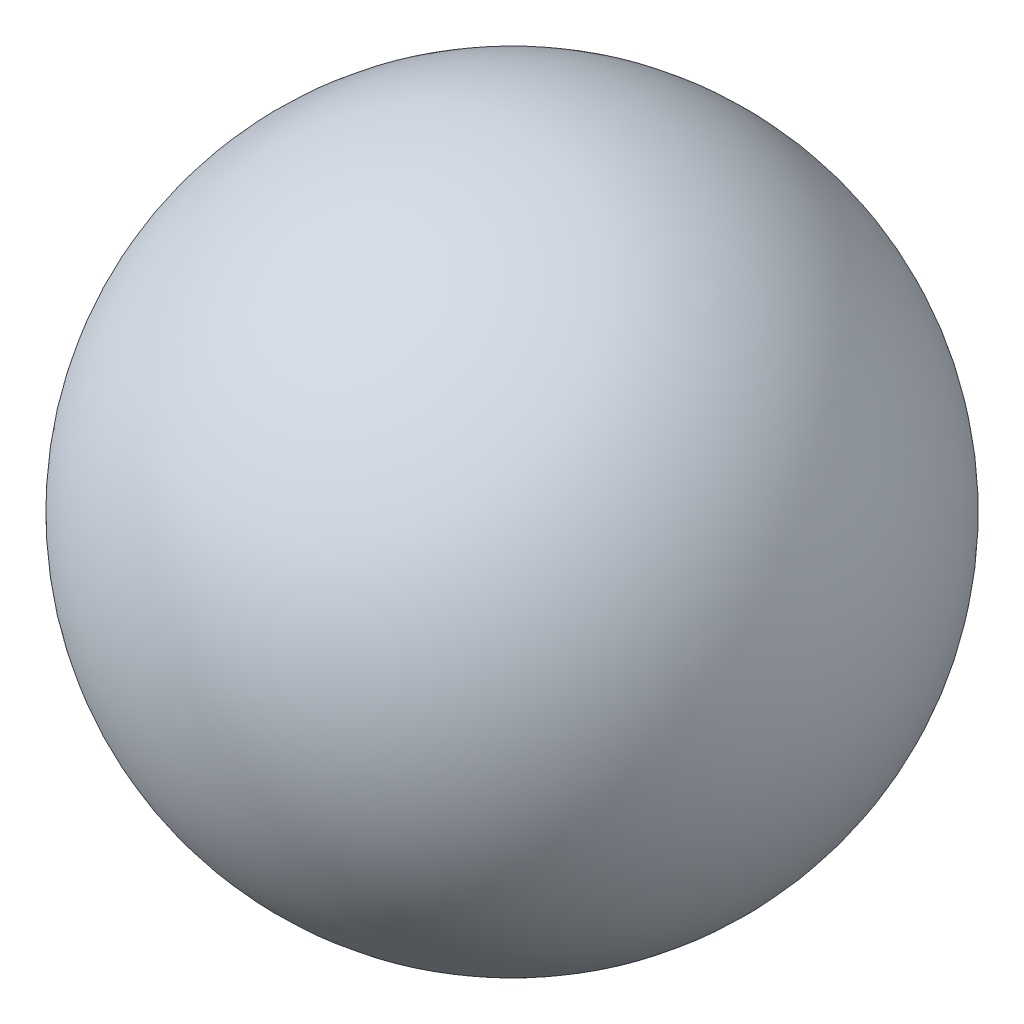
from build123d import *


with BuildPart() as part:
    # Sketch1 → Revolve1 (revolve)
    with BuildSketch(Plane.XY):
        with BuildLine():
            Line((0, 101.859163579), (0, -101.859163579))
            ThreePointArc((0, -101.859163579), (-101.859163579, 0), (0, 101.859163579))
        make_face()
    revolve(axis=Axis((0, 101.859163579, 0), (0, -1, 0)))


solid = part.part
